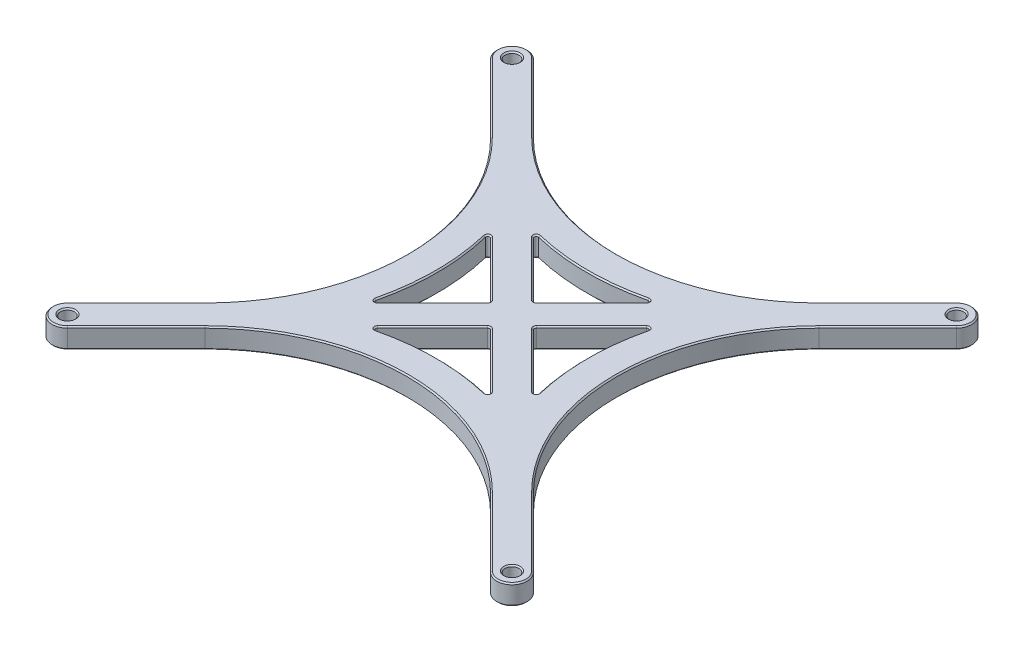
from build123d import *

# Parameters (mm, degrees)
SKETCH1_R           = 2.1828125
BOSS_EXTRUDE1_DEPTH = 6.35
CHAMFER1_SIZE       = 0.396875


with BuildPart() as part:
    # Sketch1 → Boss-Extrude1 (new body)
    with BuildSketch(Plane(origin=(0, 0, 0), x_dir=(1, 0, 0), z_dir=(0, 1, 0))):
        with BuildLine():
            Line((-3.367596045, 3.367596045), (18.213527304, 24.948719395))
            ThreePointArc((18.213527304, 24.948719395), (36.812246699, 69.85), (18.213527304, 114.751280605))
            Line((18.213527304, 114.751280605), (-3.367596045, 136.332403955))
            ThreePointArc((-3.367596045, 136.332403955), (-3.367596045, 143.067596045), (3.367596045, 143.067596045))
            Line((3.367596045, 143.067596045), (24.948719395, 121.486472696))
            ThreePointArc((24.948719395, 121.486472696), (69.85, 102.887753301), (114.751280605, 121.486472696))
            Line((114.751280605, 121.486472696), (136.332403955, 143.067596045))
            ThreePointArc((136.332403955, 143.067596045), (143.067596045, 143.067596045), (143.067596045, 136.332403955))
            Line((143.067596045, 136.332403955), (121.486472696, 114.751280605))
            ThreePointArc((121.486472696, 114.751280605), (102.887753301, 69.85), (121.486472696, 24.948719395))
            Line((121.486472696, 24.948719395), (143.067596045, 3.367596045))
            ThreePointArc((143.067596045, 3.367596045), (143.067596045, -3.367596045), (136.332403955, -3.367596045))
            Line((136.332403955, -3.367596045), (114.751280605, 18.213527304))
            ThreePointArc((114.751280605, 18.213527304), (69.85, 36.812246699), (24.948719395, 18.213527304))
            Line((24.948719395, 18.213527304), (3.367596045, -3.367596045))
            ThreePointArc((3.367596045, -3.367596045), (-3.367596045, -3.367596045), (-3.367596045, 3.367596045))
        make_face()
        with Locations((0, 139.7)):
            Circle(SKETCH1_R, mode=Mode.SUBTRACT)
        Circle(SKETCH1_R, mode=Mode.SUBTRACT)
        with Locations((139.7, 0)):
            Circle(SKETCH1_R, mode=Mode.SUBTRACT)
        with Locations((139.7, 139.7)):
            Circle(SKETCH1_R, mode=Mode.SUBTRACT)
        with BuildLine():
            Line((45.359313119, 52.094505209), (62.665795103, 69.400987194))
            ThreePointArc((62.665795103, 69.400987194), (62.851782297, 69.85), (62.665795103, 70.299012806))
            Line((62.665795103, 70.299012806), (45.359313119, 87.605494791))
            ThreePointArc((45.359313119, 87.605494791), (44.599596932, 87.71027654), (44.293075712, 87.007288174))
            ThreePointArc((44.293075712, 87.007288174), (46.337246699, 69.85), (44.293075712, 52.692711826))
            ThreePointArc((44.293075712, 52.692711826), (44.599596932, 51.98972346), (45.359313119, 52.094505209))
        make_face(mode=Mode.SUBTRACT)
        with BuildLine():
            Line((94.340686881, 87.605494791), (77.034204897, 70.299012806))
            ThreePointArc((77.034204897, 70.299012806), (76.848217703, 69.85), (77.034204897, 69.400987194))
            Line((77.034204897, 69.400987194), (94.340686881, 52.094505209))
            ThreePointArc((94.340686881, 52.094505209), (95.100403068, 51.98972346), (95.406924288, 52.692711826))
            ThreePointArc((95.406924288, 52.692711826), (93.362753301, 69.85), (95.406924288, 87.007288174))
            ThreePointArc((95.406924288, 87.007288174), (95.100403068, 87.71027654), (94.340686881, 87.605494791))
        make_face(mode=Mode.SUBTRACT)
        with BuildLine():
            Line((87.605494791, 45.359313119), (70.299012806, 62.665795103))
            ThreePointArc((70.299012806, 62.665795103), (69.85, 62.851782297), (69.400987194, 62.665795103))
            Line((69.400987194, 62.665795103), (52.094505209, 45.359313119))
            ThreePointArc((52.094505209, 45.359313119), (51.98972346, 44.599596932), (52.692711826, 44.293075712))
            ThreePointArc((52.692711826, 44.293075712), (69.85, 46.337246699), (87.007288174, 44.293075712))
            ThreePointArc((87.007288174, 44.293075712), (87.71027654, 44.599596932), (87.605494791, 45.359313119))
        make_face(mode=Mode.SUBTRACT)
        with BuildLine():
            Line((52.094505209, 94.340686881), (69.400987194, 77.034204897))
            ThreePointArc((69.400987194, 77.034204897), (69.85, 76.848217703), (70.299012806, 77.034204897))
            Line((70.299012806, 77.034204897), (87.605494791, 94.340686881))
            ThreePointArc((87.605494791, 94.340686881), (87.71027654, 95.100403068), (87.007288174, 95.406924288))
            ThreePointArc((87.007288174, 95.406924288), (69.85, 93.362753301), (52.692711826, 95.406924288))
            ThreePointArc((52.692711826, 95.406924288), (51.98972346, 95.100403068), (52.094505209, 94.340686881))
        make_face(mode=Mode.SUBTRACT)
    extrude(amount=BOSS_EXTRUDE1_DEPTH)

    # Chamfer1
    chamfer1_edges = [part.edges().sort_by_distance(p)[0] for p in [
        (125.54184228, 6.35, -132.277034371),
        (69.85, 6.35, -102.887753301),
        (14.15815772, 6.35, -132.277034371),
        (-3.367596045, 6.35, -143.067596045),
        (7.422965629, 6.35, -125.54184228),
        (36.812246699, 6.35, -69.85),
        (7.422965629, 6.35, -14.15815772),
        (-3.367596045, 6.35, 3.367596045),
        (44.599596932, 6.35, -51.98972346),
        (85.687445889, 6.35, -60.747746202),
        (76.848217703, 6.35, -69.85),
        (85.687445889, 6.35, -78.952253798),
        (95.100403068, 6.35, -87.71027654),
        (93.362753301, 6.35, -69.85),
        (95.100403068, 6.35, -51.98972346),
        (78.952253798, 6.35, -85.687445889),
        (69.85, 6.35, -76.848217703),
        (60.747746202, 6.35, -85.687445889),
        (51.98972346, 6.35, -95.100403068),
        (46.337246699, 6.35, -69.85),
        (69.85, 6.35, -93.362753301),
        (87.71027654, 6.35, -95.100403068),
        (69.85, 6.35, -46.337246699),
        (51.98972346, 6.35, -44.599596932),
        (60.747746202, 6.35, -54.012554111),
        (69.85, 6.35, -62.851782297),
        (78.952253798, 6.35, -54.012554111),
        (87.71027654, 6.35, -44.599596932),
        (44.599596932, 6.35, -87.71027654),
        (54.012554111, 6.35, -78.952253798),
        (62.851782297, 6.35, -69.85),
        (54.012554111, 6.35, -60.747746202),
        (-2.1828125, 6.35, -139.7),
        (87.71027654, 0, -44.599596932),
        (-2.1828125, 6.35, 0),
        (78.952253798, 0, -54.012554111),
        (69.85, 0, -62.851782297),
        (60.747746202, 0, -54.012554111),
        (51.98972346, 0, -44.599596932),
        (69.85, 0, -46.337246699),
        (87.71027654, 0, -95.100403068),
        (69.85, 0, -93.362753301),
        (51.98972346, 0, -95.100403068),
        (60.747746202, 0, -85.687445889),
        (69.85, 0, -76.848217703),
        (137.5171875, 6.35, 0),
        (78.952253798, 0, -85.687445889),
        (95.100403068, 0, -51.98972346),
        (93.362753301, 0, -69.85),
        (95.100403068, 0, -87.71027654),
        (85.687445889, 0, -78.952253798),
        (76.848217703, 0, -69.85),
        (85.687445889, 0, -60.747746202),
        (-3.367596045, 0, 3.367596045),
        (7.422965629, 0, -14.15815772),
        (36.812246699, 0, -69.85),
        (137.5171875, 6.35, -139.7),
        (7.422965629, 0, -125.54184228),
        (-3.367596045, 0, -143.067596045),
        (14.15815772, 0, -132.277034371),
        (69.85, 0, -102.887753301),
        (125.54184228, 0, -132.277034371),
        (143.067596045, 0, -143.067596045),
        (132.277034371, 0, -125.54184228),
        (102.887753301, 0, -69.85),
        (132.277034371, 0, -14.15815772),
        (143.067596045, 0, 3.367596045),
        (14.15815772, 6.35, -7.422965629),
        (125.54184228, 0, -7.422965629),
        (69.85, 0, -36.812246699),
        (14.15815772, 0, -7.422965629),
        (137.5171875, 0, -139.7),
        (137.5171875, 0, 0),
        (-2.1828125, 0, 0),
        (-2.1828125, 0, -139.7),
        (54.012554111, 0, -60.747746202),
        (62.851782297, 0, -69.85),
        (54.012554111, 0, -78.952253798),
        (69.85, 6.35, -36.812246699),
        (44.599596932, 0, -87.71027654),
        (46.337246699, 0, -69.85),
        (44.599596932, 0, -51.98972346),
        (125.54184228, 6.35, -7.422965629),
        (143.067596045, 6.35, 3.367596045),
        (132.277034371, 6.35, -14.15815772),
        (102.887753301, 6.35, -69.85),
        (132.277034371, 6.35, -125.54184228),
        (143.067596045, 6.35, -143.067596045),
    ]]
    chamfer(chamfer1_edges, length=CHAMFER1_SIZE)


solid = part.part
